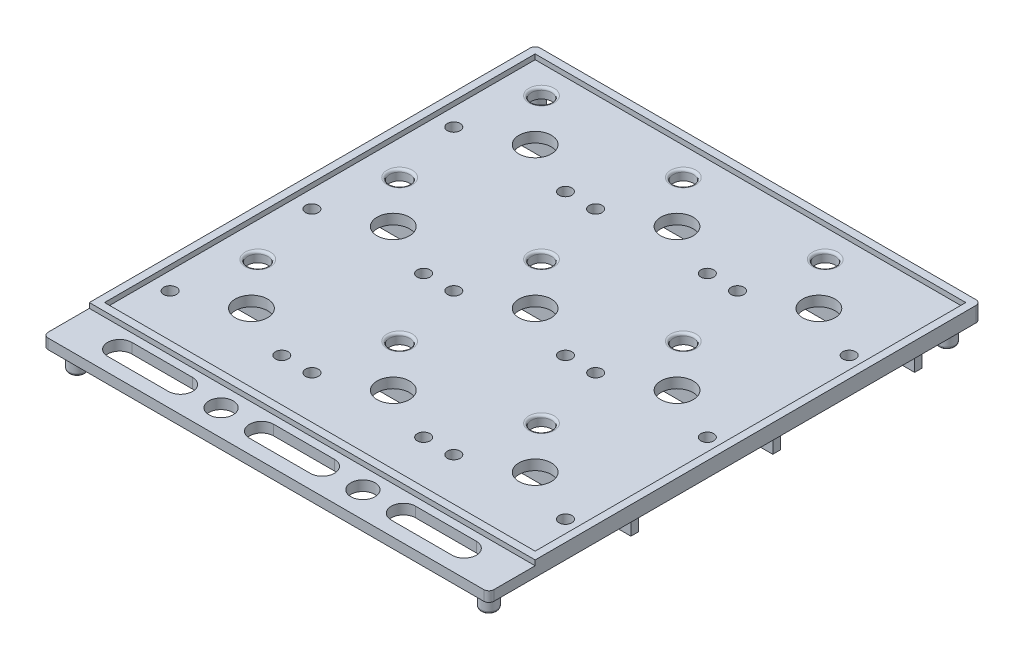
from build123d import *

# Parameters (mm, degrees)
SKETCH1_W            = 139.7
SKETCH1_H            = 154.20848
SKETCH1_R            = 2
SKETCH1_R_2          = 5.08
BOSS_EXTRUDE4_DEPTH  = 3.175
SKETCH4_W            = 139.7
SKETCH4_H            = 2.38125
BOSS_EXTRUDE7_DEPTH  = 1.5875
CUT_EXTRUDE1_REACH   = 157.518
SKETCH5_R            = 3.175
CUT_EXTRUDE2_REACH   = 157.518
SKETCH7_R            = 3.794925378
FILLET1_R            = 0.79375
SKETCH8_W            = 139.7
SKETCH8_H            = 2.38125
BOSS_EXTRUDE8_DEPTH  = 6.35
LPATTERN2_COUNT      = 3
LPATTERN2_PITCH      = 44.45
SKETCH9_W            = 139.7
SKETCH9_H            = 154.20848
SKETCH9_W_2          = 134.62
SKETCH9_H_2          = 149.12848
CUT_EXTRUDE3_DEPTH   = 6.35
SKETCH10_W           = 139.7
SKETCH10_H           = 139.7
SKETCH10_W_2         = 134.9375
SKETCH10_H_2         = 134.9375
BOSS_EXTRUDE9_DEPTH  = 1.5875
SKETCH11_R           = 2.54
BOSS_EXTRUDE10_DEPTH = 6.35
FILLET5_R            = 0.79375
FILLET6_R            = 1.5875


with BuildPart() as part:
    # Sketch1 → Boss-Extrude4 (new body)
    with BuildSketch(Plane(origin=(0, 0, 0), x_dir=(1, 0, 0), z_dir=(0, 1, 0))):
        with Locations((44.4494, 28.305760002)):
            Rectangle(SKETCH1_W, SKETCH1_H)
        with Locations((-17.5, -16.889999998)):
            Circle(SKETCH1_R, mode=Mode.SUBTRACT)
        with Locations((17.5, -16.889999998)):
            Circle(SKETCH1_R, mode=Mode.SUBTRACT)
        with Locations((26.95, -16.889999998)):
            Circle(SKETCH1_R, mode=Mode.SUBTRACT)
        with Locations((0, -8.889999998)):
            Circle(SKETCH1_R_2, mode=Mode.SUBTRACT)
        with Locations((-17.5, 27.560000002)):
            Circle(SKETCH1_R, mode=Mode.SUBTRACT)
        with Locations((17.5, 27.560000002)):
            Circle(SKETCH1_R, mode=Mode.SUBTRACT)
        with Locations((26.95, 27.560000002)):
            Circle(SKETCH1_R, mode=Mode.SUBTRACT)
        with Locations((61.95, -16.889999998)):
            Circle(SKETCH1_R, mode=Mode.SUBTRACT)
        with Locations((71.4, -16.889999998)):
            Circle(SKETCH1_R, mode=Mode.SUBTRACT)
        with Locations((106.4, -16.889999998)):
            Circle(SKETCH1_R, mode=Mode.SUBTRACT)
        with Locations((44.45, -8.889999998)):
            Circle(SKETCH1_R_2, mode=Mode.SUBTRACT)
        with Locations((61.95, 27.560000002)):
            Circle(SKETCH1_R, mode=Mode.SUBTRACT)
        with Locations((71.4, 27.560000002)):
            Circle(SKETCH1_R, mode=Mode.SUBTRACT)
        with Locations((88.9, -8.889999998)):
            Circle(SKETCH1_R_2, mode=Mode.SUBTRACT)
        with Locations((106.4, 27.560000002)):
            Circle(SKETCH1_R, mode=Mode.SUBTRACT)
        with Locations((0, 35.560000002)):
            Circle(SKETCH1_R_2, mode=Mode.SUBTRACT)
        with Locations((-17.5, 72.010000002)):
            Circle(SKETCH1_R, mode=Mode.SUBTRACT)
        with Locations((0, 80.010000002)):
            Circle(SKETCH1_R_2, mode=Mode.SUBTRACT)
        with Locations((17.5, 72.010000002)):
            Circle(SKETCH1_R, mode=Mode.SUBTRACT)
        with Locations((26.95, 72.010000002)):
            Circle(SKETCH1_R, mode=Mode.SUBTRACT)
        with Locations((44.45, 35.560000002)):
            Circle(SKETCH1_R_2, mode=Mode.SUBTRACT)
        with Locations((88.9, 35.560000002)):
            Circle(SKETCH1_R_2, mode=Mode.SUBTRACT)
        with Locations((44.45, 80.010000002)):
            Circle(SKETCH1_R_2, mode=Mode.SUBTRACT)
        with Locations((61.95, 72.010000002)):
            Circle(SKETCH1_R, mode=Mode.SUBTRACT)
        with Locations((71.4, 72.010000002)):
            Circle(SKETCH1_R, mode=Mode.SUBTRACT)
        with Locations((88.9, 80.010000002)):
            Circle(SKETCH1_R_2, mode=Mode.SUBTRACT)
        with Locations((106.4, 72.010000002)):
            Circle(SKETCH1_R, mode=Mode.SUBTRACT)
    extrude(amount=BOSS_EXTRUDE4_DEPTH)

    # Sketch4 → Boss-Extrude7 (add)
    with BuildSketch(Plane(origin=(0, 3.175, 0), x_dir=(1, 0, 0), z_dir=(0, 1, 0))):
        with Locations((44.4494, -33.099374998)):
            Rectangle(SKETCH4_W, SKETCH4_H)
    extrude(amount=BOSS_EXTRUDE7_DEPTH)

    # Sketch5 → Cut-Extrude1 (cut, up to next)
    with BuildSketch(Plane.XZ.offset(-3.175), mode=Mode.PRIVATE) as cut_extrude1_sk1:
        with Locations((-12.303725, -94.300000002)):
            Circle(SKETCH5_R)
    cut_extrude1_tool1 = extrude(cut_extrude1_sk1.sketch, amount=CUT_EXTRUDE1_REACH, mode=Mode.PRIVATE) & part.part
    # Sketch5 → Cut-Extrude1 (cut, up to next)
    with BuildSketch(Plane.XZ.offset(-3.175), mode=Mode.PRIVATE) as cut_extrude1_sk2:
        with Locations((32.146275, -94.300000002)):
            Circle(SKETCH5_R)
    cut_extrude1_tool2 = extrude(cut_extrude1_sk2.sketch, amount=CUT_EXTRUDE1_REACH, mode=Mode.PRIVATE) & part.part
    # Sketch5 → Cut-Extrude1 (cut, up to next)
    with BuildSketch(Plane.XZ.offset(-3.175), mode=Mode.PRIVATE) as cut_extrude1_sk3:
        with Locations((76.596275, -94.300000002)):
            Circle(SKETCH5_R)
    cut_extrude1_tool3 = extrude(cut_extrude1_sk3.sketch, amount=CUT_EXTRUDE1_REACH, mode=Mode.PRIVATE) & part.part
    # Sketch5 → Cut-Extrude1 (cut, up to next)
    with BuildSketch(Plane.XZ.offset(-3.175), mode=Mode.PRIVATE) as cut_extrude1_sk4:
        with Locations((32.146275, -49.850000002)):
            Circle(SKETCH5_R)
    cut_extrude1_tool4 = extrude(cut_extrude1_sk4.sketch, amount=CUT_EXTRUDE1_REACH, mode=Mode.PRIVATE) & part.part
    # Sketch5 → Cut-Extrude1 (cut, up to next)
    with BuildSketch(Plane.XZ.offset(-3.175), mode=Mode.PRIVATE) as cut_extrude1_sk5:
        with Locations((76.596275, -49.850000002)):
            Circle(SKETCH5_R)
    cut_extrude1_tool5 = extrude(cut_extrude1_sk5.sketch, amount=CUT_EXTRUDE1_REACH, mode=Mode.PRIVATE) & part.part
    # Sketch5 → Cut-Extrude1 (cut, up to next)
    with BuildSketch(Plane.XZ.offset(-3.175), mode=Mode.PRIVATE) as cut_extrude1_sk6:
        with Locations((32.146275, -5.400000002)):
            Circle(SKETCH5_R)
    cut_extrude1_tool6 = extrude(cut_extrude1_sk6.sketch, amount=CUT_EXTRUDE1_REACH, mode=Mode.PRIVATE) & part.part
    # Sketch5 → Cut-Extrude1 (cut, up to next)
    with BuildSketch(Plane.XZ.offset(-3.175), mode=Mode.PRIVATE) as cut_extrude1_sk7:
        with Locations((76.596275, -5.400000002)):
            Circle(SKETCH5_R)
    cut_extrude1_tool7 = extrude(cut_extrude1_sk7.sketch, amount=CUT_EXTRUDE1_REACH, mode=Mode.PRIVATE) & part.part
    # Sketch5 → Cut-Extrude1 (cut, up to next)
    with BuildSketch(Plane.XZ.offset(-3.175), mode=Mode.PRIVATE) as cut_extrude1_sk8:
        with Locations((-12.303725, -49.850000002)):
            Circle(SKETCH5_R)
    cut_extrude1_tool8 = extrude(cut_extrude1_sk8.sketch, amount=CUT_EXTRUDE1_REACH, mode=Mode.PRIVATE) & part.part
    # Sketch5 → Cut-Extrude1 (cut, up to next)
    with BuildSketch(Plane.XZ.offset(-3.175), mode=Mode.PRIVATE) as cut_extrude1_sk9:
        with Locations((-12.303725, -5.400000002)):
            Circle(SKETCH5_R)
    cut_extrude1_tool9 = extrude(cut_extrude1_sk9.sketch, amount=CUT_EXTRUDE1_REACH, mode=Mode.PRIVATE) & part.part
    add(cut_extrude1_tool1.solids().sort_by_distance((-12.303725, 3.175, -94.3))[0], mode=Mode.SUBTRACT)
    add(cut_extrude1_tool2.solids().sort_by_distance((32.146275, 3.175, -94.3))[0], mode=Mode.SUBTRACT)
    add(cut_extrude1_tool3.solids().sort_by_distance((76.596275, 3.175, -94.3))[0], mode=Mode.SUBTRACT)
    add(cut_extrude1_tool4.solids().sort_by_distance((32.146275, 3.175, -49.85))[0], mode=Mode.SUBTRACT)
    add(cut_extrude1_tool5.solids().sort_by_distance((76.596275, 3.175, -49.85))[0], mode=Mode.SUBTRACT)
    add(cut_extrude1_tool6.solids().sort_by_distance((32.146275, 3.175, -5.4))[0], mode=Mode.SUBTRACT)
    add(cut_extrude1_tool7.solids().sort_by_distance((76.596275, 3.175, -5.4))[0], mode=Mode.SUBTRACT)
    add(cut_extrude1_tool8.solids().sort_by_distance((-12.303725, 3.175, -49.85))[0], mode=Mode.SUBTRACT)
    add(cut_extrude1_tool9.solids().sort_by_distance((-12.303725, 3.175, -5.4))[0], mode=Mode.SUBTRACT)

    # Sketch7 → Cut-Extrude2 (cut, up to next)
    with BuildSketch(Plane(origin=(0, 3.175, 0), x_dir=(1, 0, 0), z_dir=(0, 1, 0)), mode=Mode.PRIVATE) as cut_extrude2_sk1:
        with Locations((22.225, -40.639999998)):
            Circle(SKETCH7_R)
    cut_extrude2_tool1 = extrude(cut_extrude2_sk1.sketch, amount=-CUT_EXTRUDE2_REACH, mode=Mode.PRIVATE) & part.part
    # Sketch7 → Cut-Extrude2 (cut, up to next)
    with BuildSketch(Plane(origin=(0, 3.175, 0), x_dir=(1, 0, 0), z_dir=(0, 1, 0)), mode=Mode.PRIVATE) as cut_extrude2_sk2:
        with Locations((66.675, -40.639999998)):
            Circle(SKETCH7_R)
    cut_extrude2_tool2 = extrude(cut_extrude2_sk2.sketch, amount=-CUT_EXTRUDE2_REACH, mode=Mode.PRIVATE) & part.part
    # Sketch7 → Cut-Extrude2 (cut, up to next)
    with BuildSketch(Plane(origin=(0, 3.175, 0), x_dir=(1, 0, 0), z_dir=(0, 1, 0)), mode=Mode.PRIVATE) as cut_extrude2_sk3:
        with BuildLine():
            Line((9.525, -44.434925376), (-9.525, -44.434925376))
            ThreePointArc((-9.525, -44.434925376), (-13.319925378, -40.639999998), (-9.525, -36.84507462))
            Line((-9.525, -36.84507462), (9.525, -36.84507462))
            ThreePointArc((9.525, -36.84507462), (13.319925378, -40.639999998), (9.525, -44.434925376))
        make_face()
    cut_extrude2_tool3 = extrude(cut_extrude2_sk3.sketch, amount=-CUT_EXTRUDE2_REACH, mode=Mode.PRIVATE) & part.part
    # Sketch7 → Cut-Extrude2 (cut, up to next)
    with BuildSketch(Plane(origin=(0, 3.175, 0), x_dir=(1, 0, 0), z_dir=(0, 1, 0)), mode=Mode.PRIVATE) as cut_extrude2_sk4:
        with BuildLine():
            Line((53.975, -44.434925376), (34.925, -44.434925376))
            ThreePointArc((34.925, -44.434925376), (31.130074622, -40.639999998), (34.925, -36.84507462))
            Line((34.925, -36.84507462), (53.975, -36.84507462))
            ThreePointArc((53.975, -36.84507462), (57.769925378, -40.639999998), (53.975, -44.434925376))
        make_face()
    cut_extrude2_tool4 = extrude(cut_extrude2_sk4.sketch, amount=-CUT_EXTRUDE2_REACH, mode=Mode.PRIVATE) & part.part
    # Sketch7 → Cut-Extrude2 (cut, up to next)
    with BuildSketch(Plane(origin=(0, 3.175, 0), x_dir=(1, 0, 0), z_dir=(0, 1, 0)), mode=Mode.PRIVATE) as cut_extrude2_sk5:
        with BuildLine():
            Line((98.425, -44.434925376), (79.375, -44.434925376))
            ThreePointArc((79.375, -44.434925376), (75.580074622, -40.639999998), (79.375, -36.84507462))
            Line((79.375, -36.84507462), (98.425, -36.84507462))
            ThreePointArc((98.425, -36.84507462), (102.219925378, -40.639999998), (98.425, -44.434925376))
        make_face()
    cut_extrude2_tool5 = extrude(cut_extrude2_sk5.sketch, amount=-CUT_EXTRUDE2_REACH, mode=Mode.PRIVATE) & part.part
    add(cut_extrude2_tool1.solids().sort_by_distance((22.225, 3.175, 40.64))[0], mode=Mode.SUBTRACT)
    add(cut_extrude2_tool2.solids().sort_by_distance((66.675, 3.175, 40.64))[0], mode=Mode.SUBTRACT)
    add(cut_extrude2_tool3.solids().sort_by_distance((0, 3.175, 40.64))[0], mode=Mode.SUBTRACT)
    add(cut_extrude2_tool4.solids().sort_by_distance((44.45, 3.175, 40.64))[0], mode=Mode.SUBTRACT)
    add(cut_extrude2_tool5.solids().sort_by_distance((88.9, 3.175, 40.64))[0], mode=Mode.SUBTRACT)

    # Fillet1
    fillet1_edges = [part.edges().sort_by_distance(p)[0] for p in [
        (-15.478725, 3.175, -49.850000002),
        (28.971275, 3.175, -49.850000002),
        (73.421275, 3.175, -49.850000002),
        (73.421275, 3.175, -94.300000002),
        (28.971275, 3.175, -94.300000002),
        (-15.478725, 3.175, -94.300000002),
        (73.421275, 3.175, -5.400000002),
        (28.971275, 3.175, -5.400000002),
        (-15.478725, 3.175, -5.400000002),
    ]]
    fillet(fillet1_edges, radius=FILLET1_R)

    # Sketch8 → Boss-Extrude8 (add)
    with BuildSketch(Plane(origin=(0, 0, 0), x_dir=(1, 0, 0), z_dir=(0, 1, 0))):
        with Locations((44.4494, -0.553124998)):
            Rectangle(SKETCH8_W, SKETCH8_H)
    boss_extrude8 = extrude(amount=-BOSS_EXTRUDE8_DEPTH)

    # LPattern2: Boss-Extrude8 ×3
    with Locations(*[(0, 0, -i * LPATTERN2_PITCH) for i in range(1, LPATTERN2_COUNT)]):
        add(boss_extrude8)

    # Sketch9 → Cut-Extrude3 (cut)
    with BuildSketch(Plane.XZ):
        with Locations((44.4494, -28.305760002)):
            Rectangle(SKETCH9_W, SKETCH9_H)
        with Locations((44.4494, -28.305760002)):
            Rectangle(SKETCH9_W_2, SKETCH9_H_2, mode=Mode.SUBTRACT)
    extrude(amount=CUT_EXTRUDE3_DEPTH, mode=Mode.SUBTRACT)

    # Sketch10 → Boss-Extrude9 (add)
    with BuildSketch(Plane(origin=(0, 3.175, 0), x_dir=(1, 0, 0), z_dir=(0, 1, 0))):
        with Locations((44.4494, 35.560000002)):
            Rectangle(SKETCH10_W, SKETCH10_H)
        with Locations((44.4494, 35.560000002)):
            Rectangle(SKETCH10_W_2, SKETCH10_H_2, mode=Mode.SUBTRACT)
    extrude(amount=BOSS_EXTRUDE9_DEPTH)

    # Sketch11 → Boss-Extrude10 (add)
    with BuildSketch(Plane.XZ):
        with Locations((-20.0666, 43.464479998)):
            Circle(SKETCH11_R)
        with Locations((108.9654, 43.464479998)):
            Circle(SKETCH11_R)
        with Locations((108.9654, -100.076000002)):
            Circle(SKETCH11_R)
        with Locations((-20.0666, -100.076000002)):
            Circle(SKETCH11_R)
    extrude(amount=BOSS_EXTRUDE10_DEPTH)

    # Fillet5
    fillet5_edges = [part.edges().sort_by_distance(p)[0] for p in [
        (-22.6066, -6.35, -100.076000002),
        (106.4254, -6.35, -100.076000002),
        (44.4494, 0, -87.156250002),
        (44.4494, 0, -42.706250002),
        (44.4494, 0, -89.537500002),
        (44.4494, 0, -45.087500002),
        (44.4494, 0, -0.637500002),
        (44.4494, 0, 1.743749998),
        (106.4254, -6.35, 43.464479998),
        (-22.6066, -6.35, 43.464479998),
    ]]
    fillet(fillet5_edges, radius=FILLET5_R)

    # Fillet6
    fillet6_edges = [part.edges().sort_by_distance(p)[0] for p in [
        (-25.4006, 1.5875, 48.798479998),
        (114.2994, 1.5875, 48.798479998),
        (114.2994, 2.38125, -105.410000002),
        (-25.4006, 2.38125, -105.410000002),
    ]]
    fillet(fillet6_edges, radius=FILLET6_R)


solid = part.part
